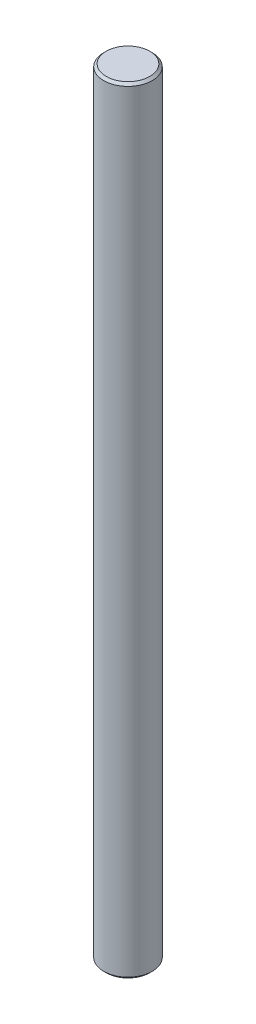
from build123d import *

# Parameters (mm, degrees)
SKETCH1_R           = 5
BOSS_EXTRUDE1_DEPTH = 160
CHAMFER1_SIZE       = 0.5


with BuildPart() as part:
    # Sketch1 → Boss-Extrude1 (new body)
    with BuildSketch(Plane(origin=(0, 0, 0), x_dir=(1, 0, 0), z_dir=(0, 1, 0))):
        Circle(SKETCH1_R)
    extrude(amount=BOSS_EXTRUDE1_DEPTH)

    # Chamfer1
    chamfer1_edges = [part.edges().sort_by_distance(p)[0] for p in [
        (-5, 0, 0),
        (-5, 160, 0),
    ]]
    chamfer(chamfer1_edges, length=CHAMFER1_SIZE)


solid = part.part
